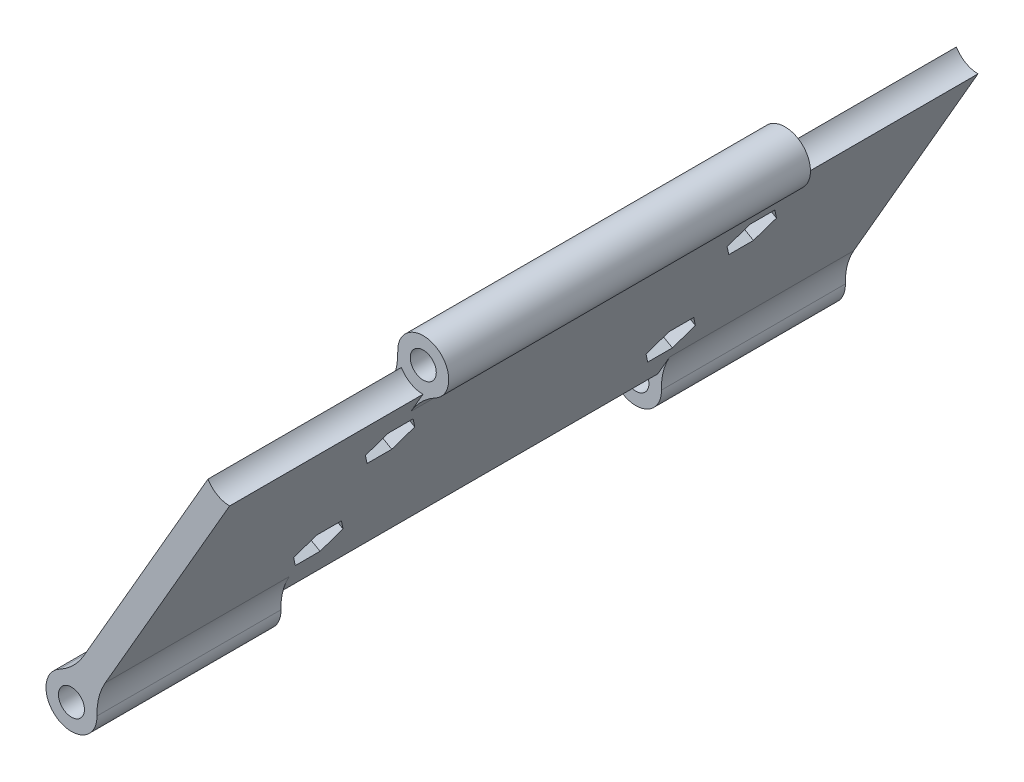
from build123d import *

# Parameters (mm, degrees)
SKETCH2_R               = 1.5875
BOSS_EXTRUDE1_DEPTH     = 10
BOSS_EXTRUDE2_DEPTH     = 120
SKETCH4_R               = 4.0875
CUT_EXTRUDE1_DEPTH      = 30.5
CUT_EXTRUDE1_DEPTH_BACK = 30.5
SKETCH5_R               = 4.0875
CUT_EXTRUDE2_DEPTH      = 31
SKETCH6_R               = 4.0875
CUT_EXTRUDE3_DEPTH      = 31
FILLET1_R               = 10
SKETCH7_R               = 2
CUT_EXTRUDE4_DEPTH      = 4
CUT_EXTRUDE5_DEPTH      = 2


with BuildPart() as part:
    # Sketch2 → Boss-Extrude1 (new body)
    with BuildSketch(Plane.XY):
        with BuildLine():
            Line((0, -27.7495), (0, 0))
            Line((0, 0), (38.1, 0))
            ThreePointArc((38.1, 0), (-26.940768363, 26.940768363), (0, -38.1))
            Line((0, -38.1), (0, -30.9245))
            ThreePointArc((0, -30.9245), (-1.5875, -29.337), (0, -27.7495))
        make_face()
        with Locations((-25.406587271, 14.6685)):
            Circle(SKETCH2_R, mode=Mode.SUBTRACT)
        with Locations((25.406587271, 14.6685)):
            Circle(SKETCH2_R, mode=Mode.SUBTRACT)
        with BuildLine():
            Line((38.1, 0), (0, 0))
            Line((0, 0), (0, -27.7495))
            ThreePointArc((0, -27.7495), (1.122532015, -28.214467985), (1.5875, -29.337))
            ThreePointArc((1.5875, -29.337), (1.122532015, -30.459532015), (0, -30.9245))
            Line((0, -30.9245), (0, -38.1))
            ThreePointArc((0, -38.1), (26.940768363, -26.940768363), (38.1, 0))
        make_face()
    extrude(amount=BOSS_EXTRUDE1_DEPTH)


with BuildPart() as body_2:
    # Sketch3 → Boss-Extrude2 (new body)
    with BuildSketch(Plane.XY.offset(10)):
        with BuildLine():
            ThreePointArc((29.494087271, 14.6685), (24.324372064, 18.610132466), (21.892146477, 12.581309985))
            Line((21.892146477, 12.581309985), (23.37551462, 15.150578976))
            ThreePointArc((23.37551462, 15.150578976), (25.649272347, 16.741845172), (27.494087271, 14.6685))
            ThreePointArc((27.494087271, 14.6685), (27.323499399, 13.841998855), (26.839616236, 13.150578976))
            Line((26.839616236, 13.150578976), (25.356248092, 10.581309985))
            ThreePointArc((25.356248092, 10.581309985), (28.279033516, 11.760457906), (29.494087271, 14.6685))
        make_face()
        with BuildLine():
            Line((24.362837271, 12.86067197), (23.362837271, 11.128621162))
            ThreePointArc((23.362837271, 11.128621162), (24.324372064, 10.726867534), (25.356248092, 10.581309985))
            Line((25.356248092, 10.581309985), (26.839616236, 13.150578976))
            ThreePointArc((26.839616236, 13.150578976), (25.649272347, 12.595154828), (24.362837271, 12.86067197))
        make_face()
        with BuildLine():
            ThreePointArc((21.892146477, 12.581309985), (22.534141026, 11.760457906), (23.362837271, 11.128621162))
            Line((23.362837271, 11.128621162), (24.362837271, 12.86067197))
            ThreePointArc((24.362837271, 12.86067197), (23.489675143, 13.841998855), (23.37551462, 15.150578976))
            Line((23.37551462, 15.150578976), (21.892146477, 12.581309985))
        make_face()
        with BuildLine():
            Line((23.362837271, 11.128621162), (2.04375, -25.797121162))
            ThreePointArc((2.04375, -25.797121162), (2.872446245, -26.428957906), (3.514440794, -27.249809985))
            Line((3.514440794, -27.249809985), (25.356248092, 10.581309985))
            ThreePointArc((25.356248092, 10.581309985), (24.324372064, 10.726867534), (23.362837271, 11.128621162))
        make_face()
        with BuildLine():
            ThreePointArc((0.050339179, -25.249809985), (1.082215206, -25.395367534), (2.04375, -25.797121162))
            Line((2.04375, -25.797121162), (23.362837271, 11.128621162))
            ThreePointArc((23.362837271, 11.128621162), (22.534141026, 11.760457906), (21.892146477, 12.581309985))
            Line((21.892146477, 12.581309985), (0.050339179, -25.249809985))
        make_face()
        with BuildLine():
            ThreePointArc((-1.433028965, -27.819078976), (-0.242685076, -27.263654828), (1.04375, -27.52917197))
            Line((1.04375, -27.52917197), (2.04375, -25.797121162))
            ThreePointArc((2.04375, -25.797121162), (1.082215206, -25.395367534), (0.050339179, -25.249809985))
            Line((0.050339179, -25.249809985), (-1.433028965, -27.819078976))
        make_face()
        with BuildLine():
            Line((2.04375, -25.797121162), (1.04375, -27.52917197))
            ThreePointArc((1.04375, -27.52917197), (1.80782803, -28.29325), (2.0875, -29.337))
            ThreePointArc((2.0875, -29.337), (2.073345172, -29.579685076), (2.03107265, -29.819078976))
            Line((2.03107265, -29.819078976), (3.514440794, -27.249809985))
            ThreePointArc((3.514440794, -27.249809985), (2.872446245, -26.428957906), (2.04375, -25.797121162))
        make_face()
        with BuildLine():
            ThreePointArc((2.03107265, -29.819078976), (-1.04375, -31.14482803), (-1.433028965, -27.819078976))
            Line((-1.433028965, -27.819078976), (0.050339179, -25.249809985))
            ThreePointArc((0.050339179, -25.249809985), (-2.908042094, -32.209446245), (4.0875, -29.337))
            ThreePointArc((4.0875, -29.337), (3.941632466, -28.254784794), (3.514440794, -27.249809985))
            Line((3.514440794, -27.249809985), (2.03107265, -29.819078976))
        make_face()
    extrude(amount=BOSS_EXTRUDE2_DEPTH)

    # Sketch4 → Cut-Extrude1 (cut, two sides)
    with BuildSketch(Plane.XY.offset(70)) as cut_extrude1_sk:
        with Locations((0, -29.337)):
            Circle(SKETCH4_R)
    extrude(amount=CUT_EXTRUDE1_DEPTH, mode=Mode.SUBTRACT)
    extrude(cut_extrude1_sk.sketch, amount=-CUT_EXTRUDE1_DEPTH_BACK, mode=Mode.SUBTRACT)

    # Sketch5 → Cut-Extrude2 (cut)
    with BuildSketch(Plane(origin=(0, 0, 10), x_dir=(-1, 0, 0), z_dir=(0, 0, -1))):
        with Locations((-25.406587271, 14.6685)):
            Circle(SKETCH5_R)
    extrude(amount=-CUT_EXTRUDE2_DEPTH, mode=Mode.SUBTRACT)

    # Sketch6 → Cut-Extrude3 (cut)
    with BuildSketch(Plane.XY.offset(130)):
        with Locations((25.406587271, 14.6685)):
            Circle(SKETCH6_R)
    extrude(amount=-CUT_EXTRUDE3_DEPTH, mode=Mode.SUBTRACT)

    # Fillet1
    fillet1_edges = [body_2.edges().sort_by_distance(p)[0] for p in [
        (0.050339179, -25.249809985, 115.25),
        (3.514440794, -27.249809985, 115.25),
        (0.050339179, -25.249809985, 24.75),
        (3.514440794, -27.249809985, 24.75),
        (21.892146477, 12.581309985, 70),
        (25.356248092, 10.581309985, 70),
    ]]
    fillet(fillet1_edges, radius=FILLET1_R)

    # Sketch7 → Cut-Extrude4 (cut)
    with BuildSketch(Plane(origin=(10.971242828, -6.33425, 0), x_dir=(0, 0, 1), z_dir=(-0.866025404, 0.5, 0))):
        with Locations((40.981352926, 11.266107412)):
            Circle(SKETCH7_R)
        with Locations((42.485061868, -11.733892588)):
            Circle(SKETCH7_R)
        with Locations((98.981352926, -11.733892588)):
            Circle(SKETCH7_R)
        with Locations((98.981352926, 11.266107412)):
            Circle(SKETCH7_R)
    extrude(amount=-CUT_EXTRUDE4_DEPTH, mode=Mode.SUBTRACT)

    # Sketch8 → Cut-Extrude5 (cut)
    with BuildSketch(Plane(origin=(14.435344443, -8.33425, 0), x_dir=(0, 0, -1), z_dir=(0.866025404, -0.5, 0))):
        Polygon((-37.02188478, 11.266107412), (-39.001618853, 14.695107412), (-42.961086999, 14.695107412), (-44.940821072, 11.266107412), (-42.961086999, 7.837107412), (-39.001618853, 7.837107412), align=None)
        Polygon((-38.525593722, -11.733892588), (-40.505327795, -8.304892588), (-44.464795941, -8.304892588), (-46.444530014, -11.733892588), (-44.464795941, -15.162892588), (-40.505327795, -15.162892588), align=None)
        Polygon((-95.02188478, 11.266107412), (-97.001618853, 14.695107412), (-100.961086999, 14.695107412), (-102.940821072, 11.266107412), (-100.961086999, 7.837107412), (-97.001618853, 7.837107412), align=None)
        Polygon((-95.02188478, -11.733892588), (-97.001618853, -8.304892588), (-100.961086999, -8.304892588), (-102.940821072, -11.733892588), (-100.961086999, -15.162892588), (-97.001618853, -15.162892588), align=None)
    extrude(amount=-CUT_EXTRUDE5_DEPTH, mode=Mode.SUBTRACT)


solid = body_2.part
